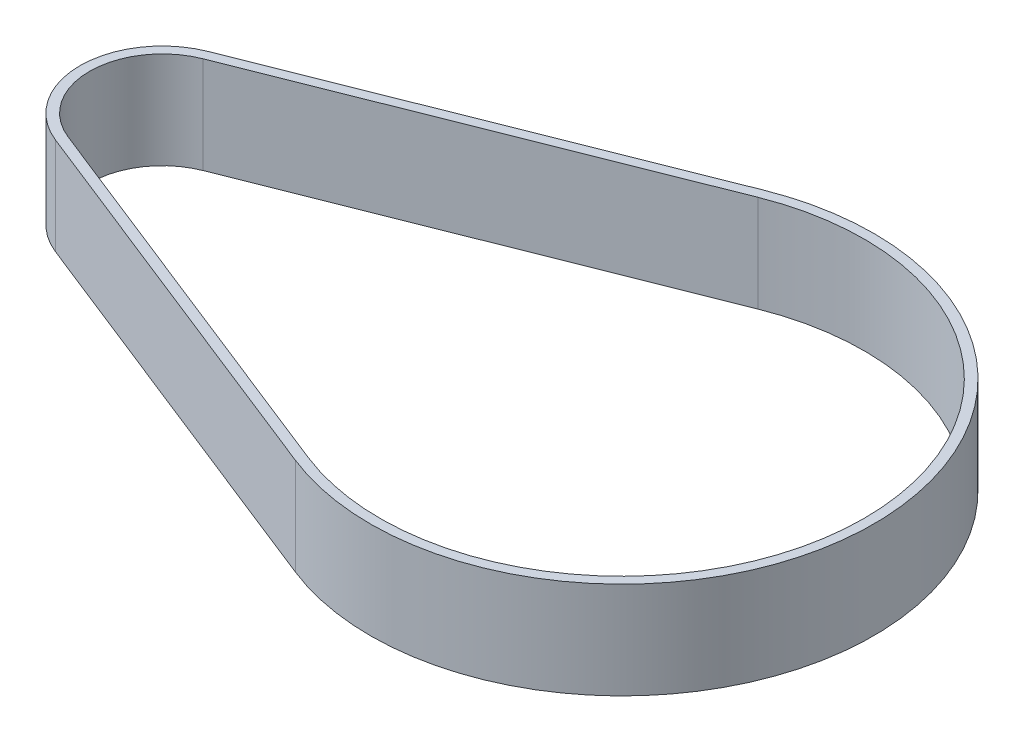
from build123d import *

# Parameters (mm, degrees)
BOSS_EXTRUDE1_DEPTH = 10


with BuildPart() as part:
    # Sketch1 → Boss-Extrude1 (new body)
    with BuildSketch(Plane(origin=(0, 0, 0), x_dir=(1, 0, 0), z_dir=(0, 1, 0))):
        with BuildLine():
            Line((-48.421216475, 7.902101828), (-7.368584896, 24.171135003))
            ThreePointArc((-7.368584896, 24.171135003), (28.210362472, 0), (-7.368584896, -24.171135003))
            Line((-7.368584896, -24.171135003), (-48.421216475, -7.902101828))
            ThreePointArc((-48.421216475, -7.902101828), (-53.789637528, 0), (-48.421216475, 7.902101828))
        make_face()
        with BuildLine():
            Line((-48.052795422, 6.972442789), (-7.000163843, 23.241475964))
            ThreePointArc((-7.000163843, 23.241475964), (27.210362472, 0), (-7.000163843, -23.241475964))
            Line((-7.000163843, -23.241475964), (-48.052795422, -6.972442789))
            ThreePointArc((-48.052795422, -6.972442789), (-52.789637528, 0), (-48.052795422, 6.972442789))
        make_face(mode=Mode.SUBTRACT)
    extrude(amount=BOSS_EXTRUDE1_DEPTH)


solid = part.part
